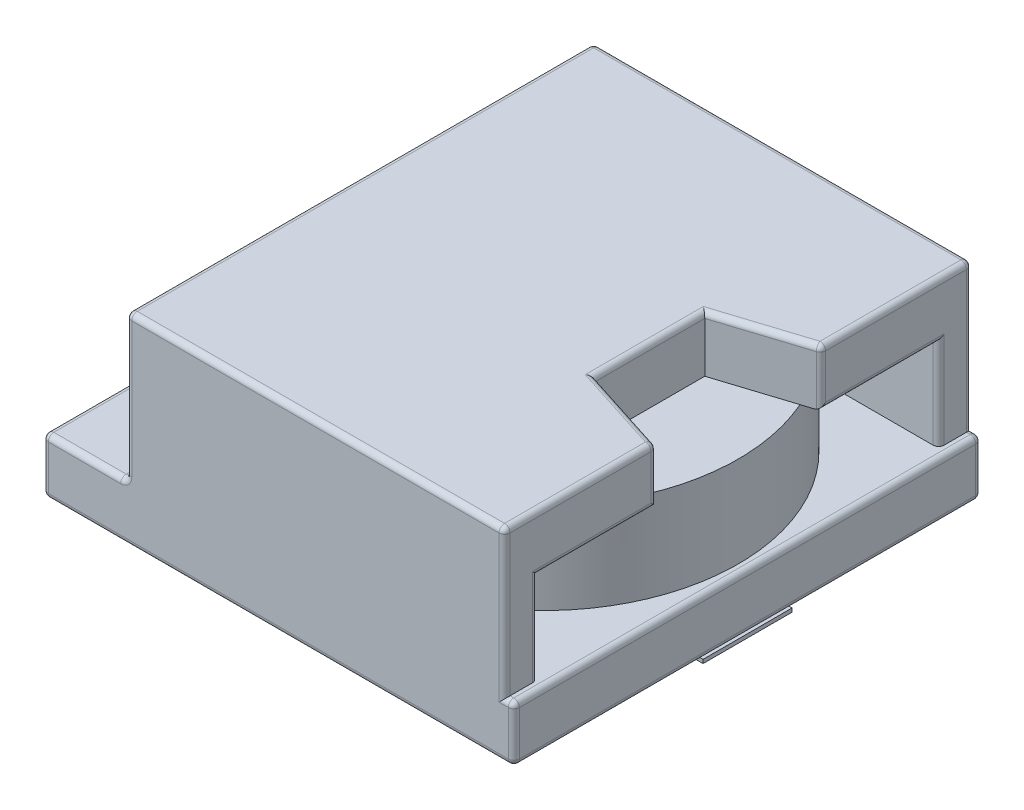
from build123d import *

# Parameters (mm, degrees)
SKETCH1_W             = 12.7
SKETCH1_H             = 12.6
BOSS_EXTRUDE1_DEPTH   = 1.5
SKETCH2_R             = 5.25
BOSS_EXTRUDE2_DEPTH   = 2.45
SKETCH3_W             = 10.2
SKETCH3_H             = 0.9
BOSS_EXTRUDE3_DEPTH   = 3.95
SKETCH4_W             = 10.2
SKETCH4_H             = 12.6
BOSS_EXTRUDE4_DEPTH   = 1.5
CUT_EXTRUDE1_DEPTH    = 1.5
SKETCH6_W             = 1.8
SKETCH6_H             = 2.8
BOSS_EXTRUDE5_DEPTH   = 0.1
BOSS_EXTRUDE5_2_DEPTH = 0.1
SKETCH6_W_2           = 1.6
SKETCH6_H_2           = 2.4
BOSS_EXTRUDE5_3_DEPTH = 0.1
FILLET1_R             = 0.15


with BuildPart() as part:
    # Sketch1 → Boss-Extrude1 (new body)
    with BuildSketch(Plane(origin=(0, 0, 0), x_dir=(1, 0, 0), z_dir=(0, 1, 0))):
        Rectangle(SKETCH1_W, SKETCH1_H)
    extrude(amount=BOSS_EXTRUDE1_DEPTH)

    # Sketch3 → Boss-Extrude3 (add)
    with BuildSketch(Plane(origin=(0, 1.5, 0), x_dir=(1, 0, 0), z_dir=(0, 1, 0))):
        with Locations((1, 5.85)):
            Rectangle(SKETCH3_W, SKETCH3_H)
        with Locations((1, -5.85)):
            Rectangle(SKETCH3_W, SKETCH3_H)
    extrude(amount=BOSS_EXTRUDE3_DEPTH)



with BuildPart() as body_2:
    # Sketch2 → Boss-Extrude2 (new body)
    with BuildSketch(Plane(origin=(0, 1.5, 0), x_dir=(1, 0, 0), z_dir=(0, 1, 0))):
        with Locations((0.85, 0)):
            Circle(SKETCH2_R)
    extrude(amount=BOSS_EXTRUDE2_DEPTH)


with BuildPart() as part_1:
    add(part.part)

    add(body_2.part)  # Boss-Extrude4 merges body 2
    # Sketch4 → Boss-Extrude4 (add)
    with BuildSketch(Plane(origin=(0, 5.45, 0), x_dir=(1, 0, 0), z_dir=(0, 1, 0))):
        with Locations((1, 0)):
            Rectangle(SKETCH4_W, SKETCH4_H)
    extrude(amount=-BOSS_EXTRUDE4_DEPTH)

    # Sketch5 → Cut-Extrude1 (cut)
    with BuildSketch(Plane(origin=(0, 5.45, 0), x_dir=(1, 0, 0), z_dir=(0, 1, 0))):
        Polygon((3.714686841, -1.48166104), (3.714686841, 1.48166104), (6.1, 2.243851), (6.1, -2.243851), align=None)
    extrude(amount=-CUT_EXTRUDE1_DEPTH, mode=Mode.SUBTRACT)

    # Fillet1
    fillet1_edges = [part_1.edges().sort_by_distance(p)[0] for p in [
        (1, 5.45, 6.3),
        (6.1, 5.45, 4.2719255),
        (1, 5.45, -6.3),
        (6.1, 3.95, 3.8219255),
        (-6.35, 0.75, 6.3),
        (0, 0, 6.3),
        (6.35, 0.75, -6.3),
        (0, 0, -6.3),
        (-4.1, 1.5, -5.85),
        (6.1, 2.725, -5.4),
        (-4.1, 1.5, 5.85),
        (6.1, 2.725, 5.4),
        (-5.225, 1.5, 6.3),
        (6.225, 1.5, 6.3),
        (6.35, 1.5, 0),
        (6.225, 1.5, -6.3),
        (-5.225, 1.5, -6.3),
        (-6.35, 1.5, 0),
        (-6.35, 0, 0),
        (-6.35, 0.75, -6.3),
        (6.35, 0, 0),
        (6.35, 0.75, 6.3),
        (6.1, 5.45, -4.2719255),
        (6.1, 3.95, -3.8219255),
        (6.1, 4.7, -2.243851),
        (6.1, 4.7, 2.243851),
        (4.90734342, 5.45, -1.86275602),
        (3.714686841, 5.45, 0),
        (4.90734342, 5.45, 1.86275602),
        (-4.1, 3.475, 6.3),
        (-4.1, 3.475, -6.3),
        (6.1, 3.475, -6.3),
        (6.1, 3.475, 6.3),
        (-4.1, 5.45, 0),
    ]]
    fillet(fillet1_edges, radius=FILLET1_R)


with BuildPart() as body_2_2:
    # Sketch6 → Boss-Extrude5 (new body)
    with BuildSketch(Plane.XZ):
        with Locations((-5.45, -3.6)):
            Rectangle(SKETCH6_W, SKETCH6_H)
    extrude(amount=BOSS_EXTRUDE5_DEPTH)


with BuildPart() as body_3:
    # Sketch6 → Boss-Extrude5 2 (new body)
    with BuildSketch(Plane.XZ):
        with Locations((-5.45, 3.6)):
            Rectangle(SKETCH6_W, SKETCH6_H)
    extrude(amount=BOSS_EXTRUDE5_2_DEPTH)


with BuildPart() as body_4:
    # Sketch6 → Boss-Extrude5 3 (new body)
    with BuildSketch(Plane.XZ):
        with Locations((5.55, 0)):
            Rectangle(SKETCH6_W_2, SKETCH6_H_2)
    extrude(amount=BOSS_EXTRUDE5_3_DEPTH)


solid = Compound([part_1.part, body_2_2.part, body_3.part, body_4.part])
